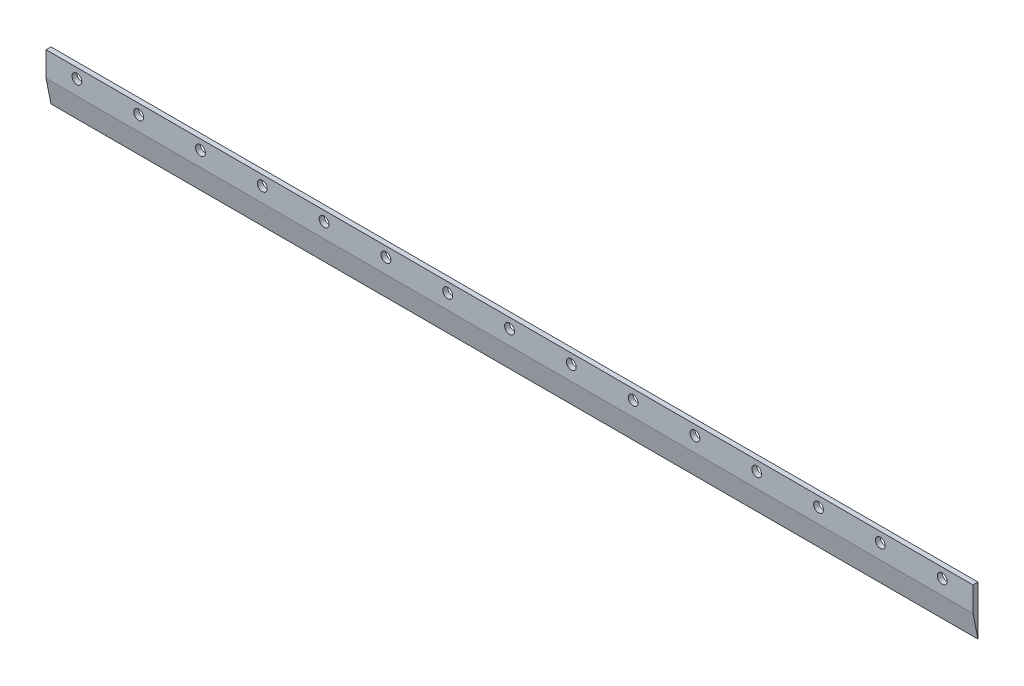
from build123d import *

# Parameters (mm, degrees)
CROQUIS1_W              = 750
CROQUIS1_H              = 40
SALIENTE_EXTRUIR1_DEPTH = 4
CORTAR_EXTRUIR1_DEPTH   = 751
CROQUIS3_R              = 3.96875
CORTAR_EXTRUIR2_DEPTH   = 10


with BuildPart() as part:
    # Croquis1 → Saliente-Extruir1 (new body)
    with BuildSketch(Plane.XY):
        Rectangle(CROQUIS1_W, CROQUIS1_H)
    extrude(amount=SALIENTE_EXTRUIR1_DEPTH)

    # Croquis2 → Cortar-Extruir1 (cut, through all)
    with BuildSketch(Plane(origin=(375, 0, 0), x_dir=(0, 0, -1), z_dir=(1, 0, 0))):
        Polygon((-4, -20), (0, -20), (-4, 0), align=None)
    extrude(amount=-CORTAR_EXTRUIR1_DEPTH, mode=Mode.SUBTRACT)

    # Croquis3 → Cortar-Extruir2 (cut)
    with BuildSketch(Plane(origin=(0, 0, 0), x_dir=(-1, 0, 0), z_dir=(0, 0, -1))):
        with Locations((-350, 12)):
            Circle(CROQUIS3_R)
        with Locations((-300, 12)):
            Circle(CROQUIS3_R)
        with Locations((-250, 12)):
            Circle(CROQUIS3_R)
        with Locations((-200, 12)):
            Circle(CROQUIS3_R)
        with Locations((-150, 12)):
            Circle(CROQUIS3_R)
        with Locations((-100, 12)):
            Circle(CROQUIS3_R)
        with Locations((-50, 12)):
            Circle(CROQUIS3_R)
        with Locations((0, 12)):
            Circle(CROQUIS3_R)
        with Locations((50, 12)):
            Circle(CROQUIS3_R)
        with Locations((100, 12)):
            Circle(CROQUIS3_R)
        with Locations((150, 12)):
            Circle(CROQUIS3_R)
        with Locations((200, 12)):
            Circle(CROQUIS3_R)
        with Locations((250, 12)):
            Circle(CROQUIS3_R)
        with Locations((300, 12)):
            Circle(CROQUIS3_R)
        with Locations((350, 12)):
            Circle(CROQUIS3_R)
    extrude(amount=-CORTAR_EXTRUIR2_DEPTH, mode=Mode.SUBTRACT)


solid = part.part
